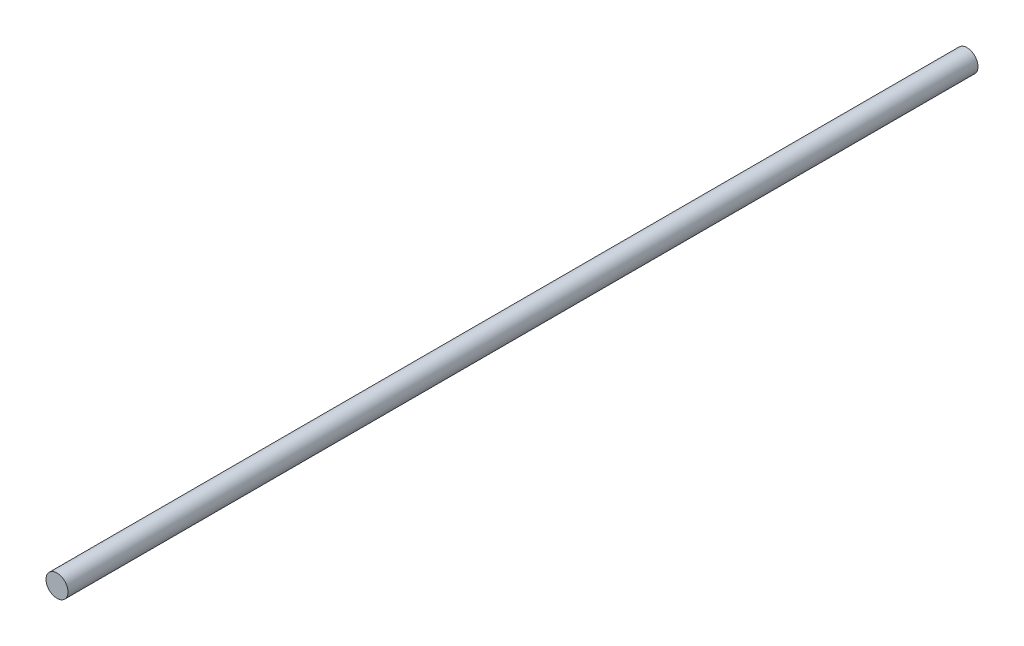
from build123d import *

# Parameters (mm, degrees)
SKETCH1_R           = 4
BOSS_EXTRUDE1_DEPTH = 331


with BuildPart() as part:
    # Sketch1 → Boss-Extrude1 (new body)
    with BuildSketch(Plane.XY):
        Circle(SKETCH1_R)
    extrude(amount=BOSS_EXTRUDE1_DEPTH)


solid = part.part
